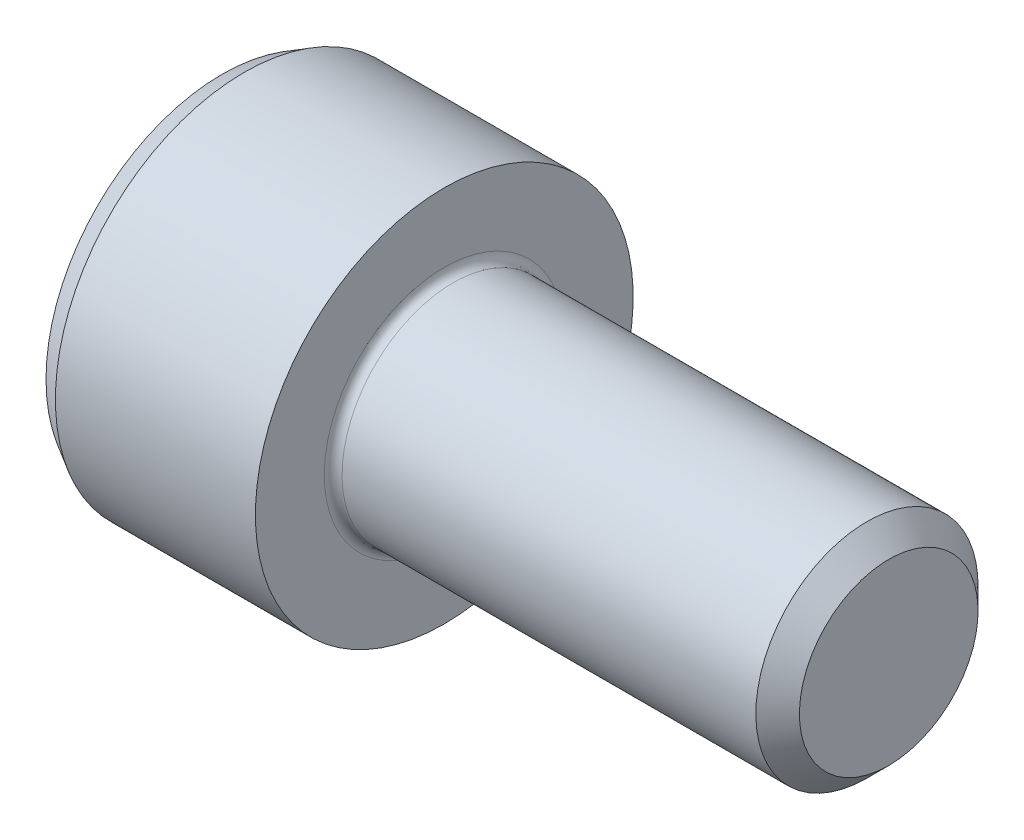
from build123d import *

# Parameters (mm, degrees)
CUT_EXTRUDE_1_DEPTH = 2.5


with BuildPart() as part:
    # ｽｹｯﾁ1 → 回転1 (revolve)
    with BuildSketch(Plane.XY):
        with BuildLine():
            Line((-5, 0), (-5, 3.961324865))
            Line((-5, 3.961324865), (-4.5, 4.25))
            Line((-4.5, 4.25), (0, 4.25))
            Line((0, 4.25), (0, 2.7))
            ThreePointArc((0, 2.7), (0.058578644, 2.558578644), (0.2, 2.5))
            Line((0.2, 2.5), (9.5095, 2.5))
            Line((9.5095, 2.5), (10, 2.0095))
            Line((10, 2.0095), (10, 0))
            Line((10, 0), (-5, 0))
        make_face()
    revolve(axis=Axis((10, 0, 0), (-1, 0, 0)))

    # ｽｹｯﾁ2 → ｶｯﾄ - 回転1 (revolve, cut)
    with BuildSketch(Plane.XY):
        Polygon((-5, 0), (-5, 2), (-2.5, 2), (-1.345299462, 0), align=None)
    revolve(axis=Axis((-1.345299462, 0, 0), (-1, 0, 0)), mode=Mode.SUBTRACT)

    # ｽｹｯﾁ3 → ｶｯﾄ - 押し出し1 (cut)
    with BuildSketch(Plane(origin=(-5, 0, 0), x_dir=(0, 0, -1), z_dir=(1, 0, 0))):
        Polygon((-2, -1.154700538), (0, -2.309401077), (2, -1.154700538), (2, 1.154700538), (0, 2.309401077), (-2, 1.154700538), align=None)
    extrude(amount=CUT_EXTRUDE_1_DEPTH, mode=Mode.SUBTRACT)


solid = part.part
